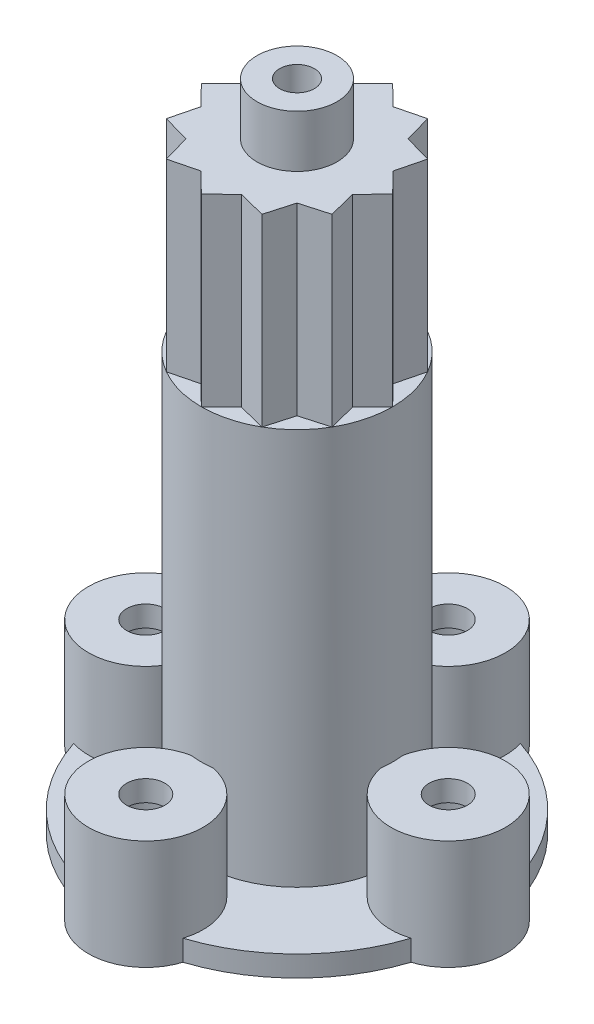
from build123d import *

# Parameters (mm, degrees)
SKETCH1_R            = 10.2
BOSS_EXTRUDE1_DEPTH  = 1.2
SKETCH3_R            = 5.5
BOSS_EXTRUDE2_DEPTH  = 22.8
SKETCH6_R            = 3.3
BOSS_EXTRUDE7_DEPTH  = 6.3
SKETCH7_R            = 2.2
CUT_EXTRUDE1_DEPTH   = 5.1
SKETCH8_R            = 1.1
CUT_EXTRUDE2_DEPTH   = 1.2
CIRPATTERN1_COUNT    = 4
SKETCH9_R            = 4.4
CUT_EXTRUDE3_DEPTH   = 22.8
SKETCH10_R           = 4.5
BOSS_EXTRUDE8_DEPTH  = 10.6
BOSS_EXTRUDE9_DEPTH  = 10.6
CIRPATTERN2_COUNT    = 12
SKETCH12_R           = 3.2
CUT_EXTRUDE4_DEPTH   = 10.6
SKETCH13_R           = 2.3
BOSS_EXTRUDE10_DEPTH = 3
SKETCH14_R           = 1
CUT_EXTRUDE5_DEPTH   = 3


with BuildPart() as part:
    # Sketch1 → Boss-Extrude1 (new body)
    with BuildSketch(Plane(origin=(0, 0, 0), x_dir=(1, 0, 0), z_dir=(0, 1, 0))):
        Circle(SKETCH1_R)
    extrude(amount=BOSS_EXTRUDE1_DEPTH)

    # Sketch3 → Boss-Extrude2 (add)
    with BuildSketch(Plane(origin=(0, 1.2, 0), x_dir=(1, 0, 0), z_dir=(0, 1, 0))):
        Circle(SKETCH3_R)
    extrude(amount=BOSS_EXTRUDE2_DEPTH)

    # Sketch6 → Boss-Extrude7 (add)
    with BuildSketch(Plane.XZ):
        with Locations((8.7, 0)):
            Circle(SKETCH6_R)
    boss_extrude7 = extrude(amount=-BOSS_EXTRUDE7_DEPTH)

    # Sketch7 → Cut-Extrude1 (cut)
    with BuildSketch(Plane.XZ):
        with Locations((8.7, 0)):
            Circle(SKETCH7_R)
    cut_extrude1 = extrude(amount=-CUT_EXTRUDE1_DEPTH, mode=Mode.SUBTRACT)

    # Sketch8 → Cut-Extrude2 (cut)
    with BuildSketch(Plane(origin=(0, 6.3, 0), x_dir=(1, 0, 0), z_dir=(0, 1, 0))):
        with Locations((8.7, 0)):
            Circle(SKETCH8_R)
    cut_extrude2 = extrude(amount=-CUT_EXTRUDE2_DEPTH, mode=Mode.SUBTRACT)

    # CirPattern1: Boss-Extrude7, Cut-Extrude1, Cut-Extrude2 ×4 about axis
    cirpattern1_axis = Axis((0, 25.2, 0), (0, -1, 0))
    add([boss_extrude7.rotate(cirpattern1_axis, i * 360 / CIRPATTERN1_COUNT) for i in range(1, CIRPATTERN1_COUNT)])
    add([cut_extrude1.rotate(cirpattern1_axis, i * 360 / CIRPATTERN1_COUNT) for i in range(1, CIRPATTERN1_COUNT)], mode=Mode.SUBTRACT)
    add([cut_extrude2.rotate(cirpattern1_axis, i * 360 / CIRPATTERN1_COUNT) for i in range(1, CIRPATTERN1_COUNT)], mode=Mode.SUBTRACT)

    # Sketch9 → Cut-Extrude3 (cut)
    with BuildSketch(Plane(origin=(0, 0, 0), x_dir=(-1, 0, 0), z_dir=(0, -1, 0))):
        Circle(SKETCH9_R)
    extrude(amount=-CUT_EXTRUDE3_DEPTH, mode=Mode.SUBTRACT)

    # Sketch10 → Boss-Extrude8 (add)
    with BuildSketch(Plane(origin=(0, 24, 0), x_dir=(1, 0, 0), z_dir=(0, 1, 0))):
        Circle(SKETCH10_R)
    extrude(amount=BOSS_EXTRUDE8_DEPTH)

    # Sketch11 → Boss-Extrude9 (add)
    with BuildSketch(Plane(origin=(0, 24, 0), x_dir=(1, 0, 0), z_dir=(0, 1, 0))):
        Polygon((-1.2, 4.337049688), (1.2, 4.337049688), (0, 5.5), align=None)
    boss_extrude9 = extrude(amount=BOSS_EXTRUDE9_DEPTH)

    # CirPattern2: Boss-Extrude9 ×12 about axis
    cirpattern2_axis = Axis((0, 25.2, 0), (0, -1, 0))
    for i in range(1, CIRPATTERN2_COUNT):
        add(boss_extrude9.rotate(cirpattern2_axis, i * 360 / CIRPATTERN2_COUNT))

    # Sketch12 → Cut-Extrude4 (cut)
    with BuildSketch(Plane.XZ.offset(-22.8)):
        Circle(SKETCH12_R)
    extrude(amount=-CUT_EXTRUDE4_DEPTH, mode=Mode.SUBTRACT)

    # Sketch13 → Boss-Extrude10 (add)
    with BuildSketch(Plane(origin=(0, 34.6, 0), x_dir=(1, 0, 0), z_dir=(0, 1, 0))):
        Circle(SKETCH13_R)
    extrude(amount=BOSS_EXTRUDE10_DEPTH)

    # Sketch14 → Cut-Extrude5 (cut)
    with BuildSketch(Plane(origin=(0, 37.6, 0), x_dir=(1, 0, 0), z_dir=(0, 1, 0))):
        Circle(SKETCH14_R)
    extrude(amount=-CUT_EXTRUDE5_DEPTH, mode=Mode.SUBTRACT)


solid = part.part
